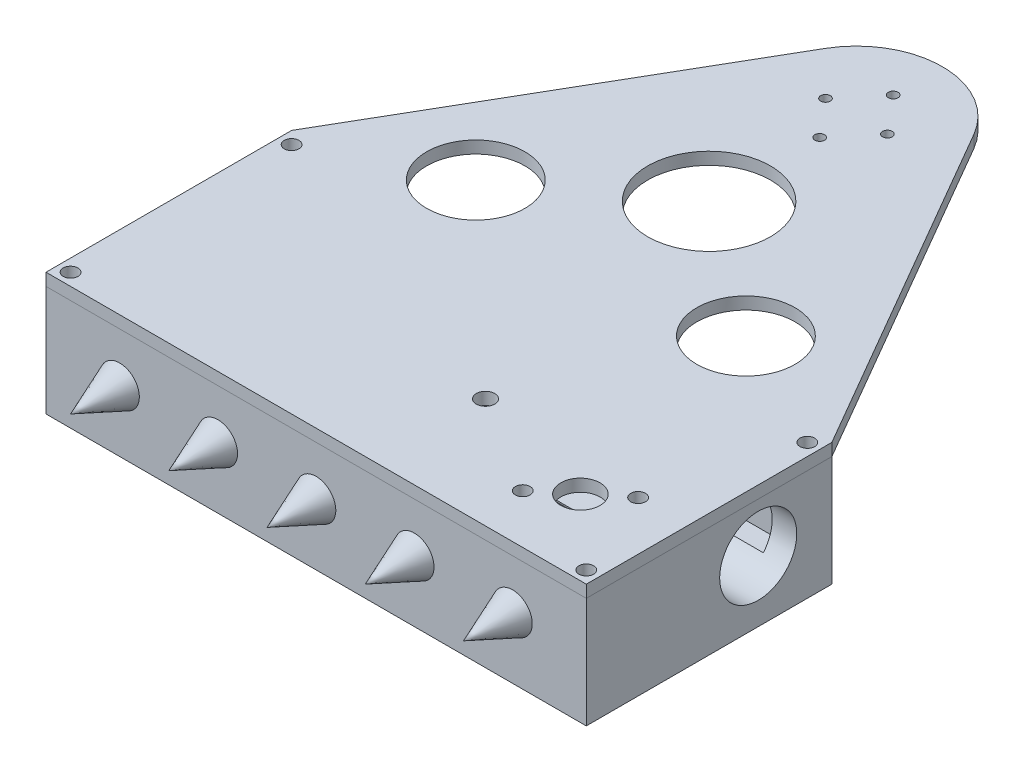
from build123d import *

# Parameters (mm, degrees)
SKETCH3_W                = 139.7
SKETCH3_H                = 63.5
SKETCH3_W_2              = 127
SKETCH3_H_2              = 50.8
BOSS_EXTRUDE1_DEPTH      = 12.7
BOSS_EXTRUDE1_DEPTH_BACK = 12.7
SKETCH4_W                = 139.7
SKETCH4_H                = 63.5
BOSS_EXTRUDE2_DEPTH      = 3.175
BOSS_EXTRUDE3_DEPTH      = 3.175
SKETCH7_W                = 44.45
SKETCH7_H                = 25.4
BOSS_EXTRUDE4_DEPTH      = 6.35
SKETCH6_R                = 9.9695
CUT_EXTRUDE1_DEPTH       = 140.7
LPATTERN1_COUNT          = 3
LPATTERN1_PITCH          = 25.4
LPATTERN1_COL_COUNT      = 3
LPATTERN1_COL_PITCH      = 25.4
SKETCH13_W               = 29.21
SKETCH13_H               = 25.4
BOSS_EXTRUDE5_DEPTH      = 4.064
SKETCH14_W               = 6.35
SKETCH14_H               = 2.54
CUT_EXTRUDE2_DEPTH       = 31.75
SKETCH18_W               = 10.16
SKETCH18_H               = 5.08
CUT_EXTRUDE3_DEPTH       = 6.35
SKETCH19_R               = 0.635
CUT_EXTRUDE4_DEPTH       = 25.4
SKETCH20_R               = 1.905
CUT_EXTRUDE7_DEPTH       = 3.175
SKETCH23_R               = 5.08
SKETCH23_R_2             = 1.905
SKETCH23_R_3             = 2.38125
CUT_EXTRUDE8_DEPTH       = 3.175
SKETCH24_R               = 1.25
CUT_EXTRUDE9_DEPTH       = 3.175
SKETCH25_R               = 15.875
SKETCH25_R_2             = 12.7
CUT_EXTRUDE10_DEPTH      = 32.75


with BuildPart() as part:
    # Sketch3 → Boss-Extrude1 (new body, two sides)
    with BuildSketch(Plane(origin=(0, 0, 0), x_dir=(1, 0, 0), z_dir=(0, 1, 0))) as boss_extrude1_sk:
        with Locations((0, -107.95)):
            Rectangle(SKETCH3_W, SKETCH3_H)
        with Locations((0, -107.95)):
            Rectangle(SKETCH3_W_2, SKETCH3_H_2, mode=Mode.SUBTRACT)
    extrude(amount=BOSS_EXTRUDE1_DEPTH)
    extrude(boss_extrude1_sk.sketch, amount=-BOSS_EXTRUDE1_DEPTH_BACK)

    # Sketch4 → Boss-Extrude2 (add)
    with BuildSketch(Plane.XZ.offset(12.7)):
        with Locations((0, 107.95)):
            Rectangle(SKETCH4_W, SKETCH4_H)
    extrude(amount=BOSS_EXTRUDE2_DEPTH)

    # Sketch7 → Boss-Extrude4 (add)
    with BuildSketch(Plane(origin=(0, -12.7, 0), x_dir=(1, 0, 0), z_dir=(0, 1, 0))):
        with Locations((-41.275, -95.25)):
            Rectangle(SKETCH7_W, SKETCH7_H)
        with Locations((41.275, -95.25)):
            Rectangle(SKETCH7_W, SKETCH7_H)
    extrude(amount=BOSS_EXTRUDE4_DEPTH)

    # Sketch6 → Cut-Extrude1 (cut, through all)
    with BuildSketch(Plane.ZY.offset(69.85)):
        with Locations((95.25, 0)):
            Circle(SKETCH6_R)
    extrude(amount=-CUT_EXTRUDE1_DEPTH, mode=Mode.SUBTRACT)

    # Sketch9 → Revolve1 (revolve)
    with BuildSketch(Plane(origin=(0, 0, 0), x_dir=(0, 0, -1), z_dir=(1, 0, 0))):
        Polygon((-139.7, 0), (-139.7, 5.08), (-152.4, 0), align=None)
    revolve1 = revolve(axis=Axis((0, 0, 152.4), (0, 0, -1)))

    # LPattern1: Revolve1 ×3
    with Locations(*[(-i * LPATTERN1_PITCH, 0, 0) for i in range(1, LPATTERN1_COUNT)]):
        add(revolve1)

    # LPattern1 col: Revolve1 ×3
    with Locations(*[(i * LPATTERN1_COL_PITCH, 0, 0) for i in range(1, LPATTERN1_COL_COUNT)]):
        add(revolve1)

    # Sketch13 → Boss-Extrude5 (add)
    with BuildSketch(Plane(origin=(0, -12.7, 0), x_dir=(1, 0, 0), z_dir=(0, 1, 0))):
        with Locations((-33.655, -95.25)):
            Rectangle(SKETCH13_W, SKETCH13_H)
        with Locations((33.655, -95.25)):
            Rectangle(SKETCH13_W, SKETCH13_H)
    extrude(amount=BOSS_EXTRUDE5_DEPTH)

    # Sketch14 → Cut-Extrude2 (cut)
    with BuildSketch(Plane.XY.offset(107.95)):
        with Locations((-40.005, -10.414)):
            Rectangle(SKETCH14_W, SKETCH14_H)
        with Locations((-40.005, -3.81)):
            Rectangle(SKETCH14_W, SKETCH14_H)
        with Locations((40.005, -10.414)):
            Rectangle(SKETCH14_W, SKETCH14_H)
        with Locations((40.005, -3.81)):
            Rectangle(SKETCH14_W, SKETCH14_H)
    extrude(amount=-CUT_EXTRUDE2_DEPTH, mode=Mode.SUBTRACT)

    # Sketch18 → Cut-Extrude3 (cut)
    with BuildSketch(Plane.XY.offset(82.55)):
        with Locations((-55.88, 10.16)):
            Rectangle(SKETCH18_W, SKETCH18_H)
    extrude(amount=-CUT_EXTRUDE3_DEPTH, mode=Mode.SUBTRACT)

    # Sketch19 → Cut-Extrude4 (cut)
    with BuildSketch(Plane(origin=(0, 12.7, 0), x_dir=(1, 0, 0), z_dir=(0, 1, 0))):
        with Locations((-66.675, -79.375)):
            Circle(SKETCH19_R)
        with Locations((66.675, -79.375)):
            Circle(SKETCH19_R)
        with Locations((-66.675, -136.525)):
            Circle(SKETCH19_R)
        with Locations((66.675, -136.525)):
            Circle(SKETCH19_R)
    extrude(amount=-CUT_EXTRUDE4_DEPTH, mode=Mode.SUBTRACT)


with BuildPart() as body_2:
    # Sketch5 → Boss-Extrude3 (new body)
    with BuildSketch(Plane(origin=(0, 12.7, 0), x_dir=(1, 0, 0), z_dir=(0, 1, 0))):
        with BuildLine():
            Line((-19.229016085, 11.144306411), (-69.85, -76.2))
            Line((-69.85, -76.2), (-69.85, -139.7))
            Line((-69.85, -139.7), (69.85, -139.7))
            Line((69.85, -139.7), (69.85, -76.2))
            Line((69.85, -76.2), (19.229016085, 11.144306411))
            ThreePointArc((19.229016085, 11.144306411), (0, 22.225), (-19.229016085, 11.144306411))
        make_face()
    extrude(amount=BOSS_EXTRUDE3_DEPTH)

    # Sketch20 → Cut-Extrude7 (cut)
    with BuildSketch(Plane(origin=(0, 15.875, 0), x_dir=(1, 0, 0), z_dir=(0, 1, 0))):
        with Locations((-66.675, -79.375)):
            Circle(SKETCH20_R)
        with Locations((-66.675, -136.525)):
            Circle(SKETCH20_R)
        with Locations((66.675, -136.525)):
            Circle(SKETCH20_R)
        with Locations((66.675, -79.375)):
            Circle(SKETCH20_R)
    extrude(amount=-CUT_EXTRUDE7_DEPTH, mode=Mode.SUBTRACT)

    # Sketch23 → Cut-Extrude8 (cut)
    with BuildSketch(Plane(origin=(0, 15.875, 0), x_dir=(1, 0, 0), z_dir=(0, 1, 0))):
        with Locations((48.932509154, -120.304266718)):
            Circle(SKETCH23_R)
        with Locations((57.15, -113.608533435)):
            Circle(SKETCH23_R_2)
        with Locations((40.715018307, -127)):
            Circle(SKETCH23_R_2)
        with Locations((15.315018307, -111.227283435)):
            Circle(SKETCH23_R_3)
    extrude(amount=-CUT_EXTRUDE8_DEPTH, mode=Mode.SUBTRACT)

    # Sketch24 → Cut-Extrude9 (cut)
    with BuildSketch(Plane(origin=(0, 15.875, 0), x_dir=(1, 0, 0), z_dir=(0, 1, 0))):
        with Locations((0, 9.5)):
            Circle(SKETCH24_R)
        with Locations((0, -9.5)):
            Circle(SKETCH24_R)
        with Locations((-8, 0)):
            Circle(SKETCH24_R)
        with Locations((8, 0)):
            Circle(SKETCH24_R)
    extrude(amount=-CUT_EXTRUDE9_DEPTH, mode=Mode.SUBTRACT)

    # Sketch25 → Cut-Extrude10 (cut, through all)
    with BuildSketch(Plane(origin=(0, 15.875, 0), x_dir=(1, 0, 0), z_dir=(0, 1, 0))):
        with Locations((0, -38.1)):
            Circle(SKETCH25_R)
        with Locations((-34.925, -63.5)):
            Circle(SKETCH25_R_2)
        with Locations((34.925, -63.5)):
            Circle(SKETCH25_R_2)
    extrude(amount=-CUT_EXTRUDE10_DEPTH, mode=Mode.SUBTRACT)


solid = Compound([part.part, body_2.part])
